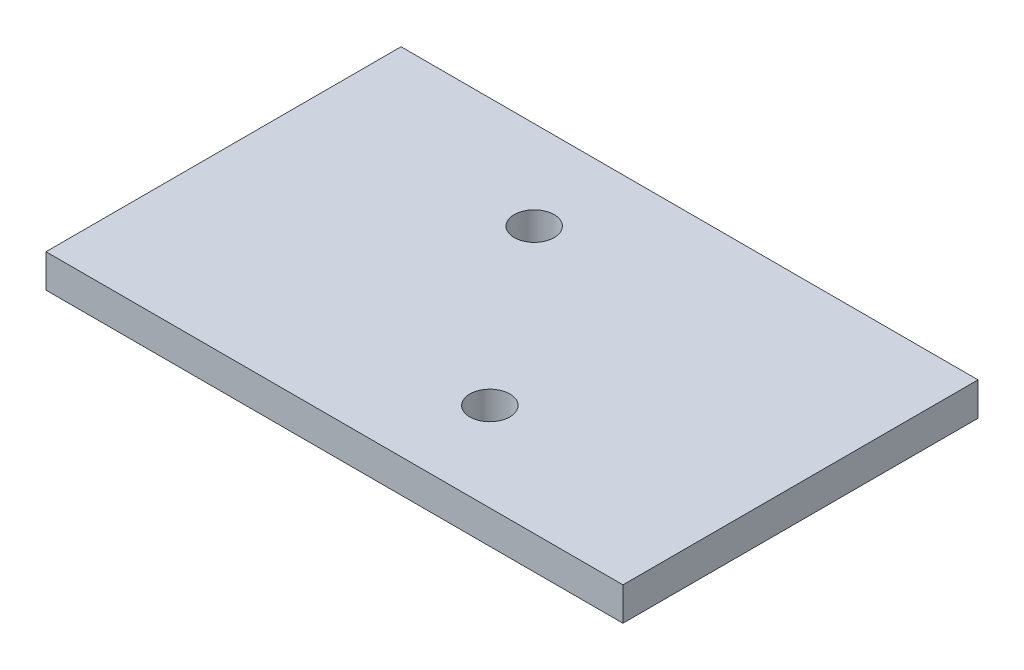
from build123d import *

# Parameters (mm, degrees)
BASE_SKETCH_W              = 26
BASE_SKETCH_H              = 16
BOSS_EXTRUDE1_DEPTH        = 1.5
F_1_8_1_8_DIAMETER_HOLE1_D = 1.8


with BuildPart() as part:
    # Base Sketch → Boss-Extrude1 (new body)
    with BuildSketch(Plane(origin=(0, 0, 0), x_dir=(1, 0, 0), z_dir=(0, 1, 0))):
        Rectangle(BASE_SKETCH_W, BASE_SKETCH_H)
    extrude(amount=BOSS_EXTRUDE1_DEPTH)

    # Ø1.8 (1.8) Diameter Hole1 (through all)
    with Locations(Plane(origin=(0, 1.5, 0), x_dir=(1, 0, 0), z_dir=(0, 1, 0))):
        with Locations((-3, 4), (3, -4)):
            Hole(F_1_8_1_8_DIAMETER_HOLE1_D / 2)


solid = part.part
